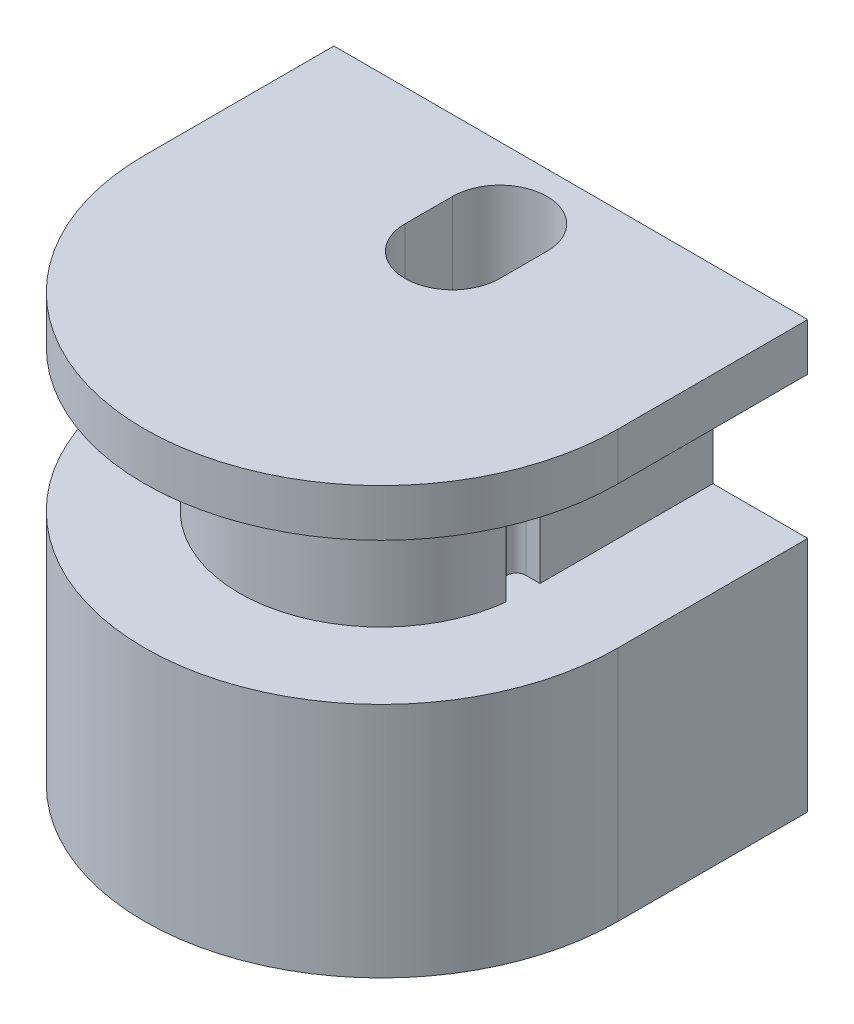
from build123d import *

# Parameters (mm, degrees)
EXTRUSION1_DEPTH = 5
EXTRUSION2_DEPTH = 3
EXTRUSION3_DEPTH = 1
EXTRUSION4_DEPTH = 10
ESQUISSE5_W      = 0.7
ESQUISSE5_H      = 3
EXTRUSION5_DEPTH = 0.5
CONG_1_R         = 0.2


with BuildPart() as part:
    # Esquisse1 → Extrusion1 (new body)
    with BuildSketch(Plane(origin=(0, 0, 0), x_dir=(1, 0, 0), z_dir=(0, 1, 0))):
        with BuildLine():
            Line((-5, 0), (5, 0))
            Line((5, 0), (5, -4))
            ThreePointArc((5, -4), (0, -9), (-5, -4))
            Line((-5, -4), (-5, 0))
        make_face()
    extrude(amount=EXTRUSION1_DEPTH)

    # Esquisse2 → Extrusion2 (add)
    with BuildSketch(Plane(origin=(0, 5, 0), x_dir=(1, 0, 0), z_dir=(0, 1, 0))):
        with BuildLine():
            Line((-3, 0), (3, 0))
            Line((3, 0), (3, -4))
            ThreePointArc((3, -4), (0, -7), (-3, -4))
            Line((-3, -4), (-3, 0))
        make_face()
    extrude(amount=EXTRUSION2_DEPTH)

    # Esquisse3 → Extrusion3 (add)
    with BuildSketch(Plane(origin=(0, 8, 0), x_dir=(1, 0, 0), z_dir=(0, 1, 0))):
        with BuildLine():
            Line((-5, 0), (5, 0))
            Line((5, 0), (5, -4))
            ThreePointArc((5, -4), (0, -9), (-5, -4))
            Line((-5, -4), (-5, 0))
        make_face()
    extrude(amount=EXTRUSION3_DEPTH)

    # Esquisse4 → Extrusion4 (cut, through all)
    with BuildSketch(Plane(origin=(0, 9, 0), x_dir=(1, 0, 0), z_dir=(0, 1, 0))):
        with BuildLine():
            Line((1, -1.5), (1, -2.5))
            ThreePointArc((1, -2.5), (0, -3.5), (-1, -2.5))
            Line((-1, -2.5), (-1, -1.5))
            ThreePointArc((-1, -1.5), (0, -0.5), (1, -1.5))
        make_face()
    extrude(amount=-EXTRUSION4_DEPTH, mode=Mode.SUBTRACT)

    # Esquisse5 → Extrusion5 (cut)
    with BuildSketch(Plane(origin=(3, 0, 0), x_dir=(0, 0, -1), z_dir=(1, 0, 0))):
        with Locations((-4, 6.5)):
            Rectangle(ESQUISSE5_W, ESQUISSE5_H)
    extrude(amount=-EXTRUSION5_DEPTH, mode=Mode.SUBTRACT)

    # Congé1
    cong_1_edges = [part.edges().sort_by_distance(p)[0] for p in [
        (2.5, 6.5, 4.35),
        (2.5, 6.5, 3.65),
    ]]
    fillet(cong_1_edges, radius=CONG_1_R)


solid = part.part
